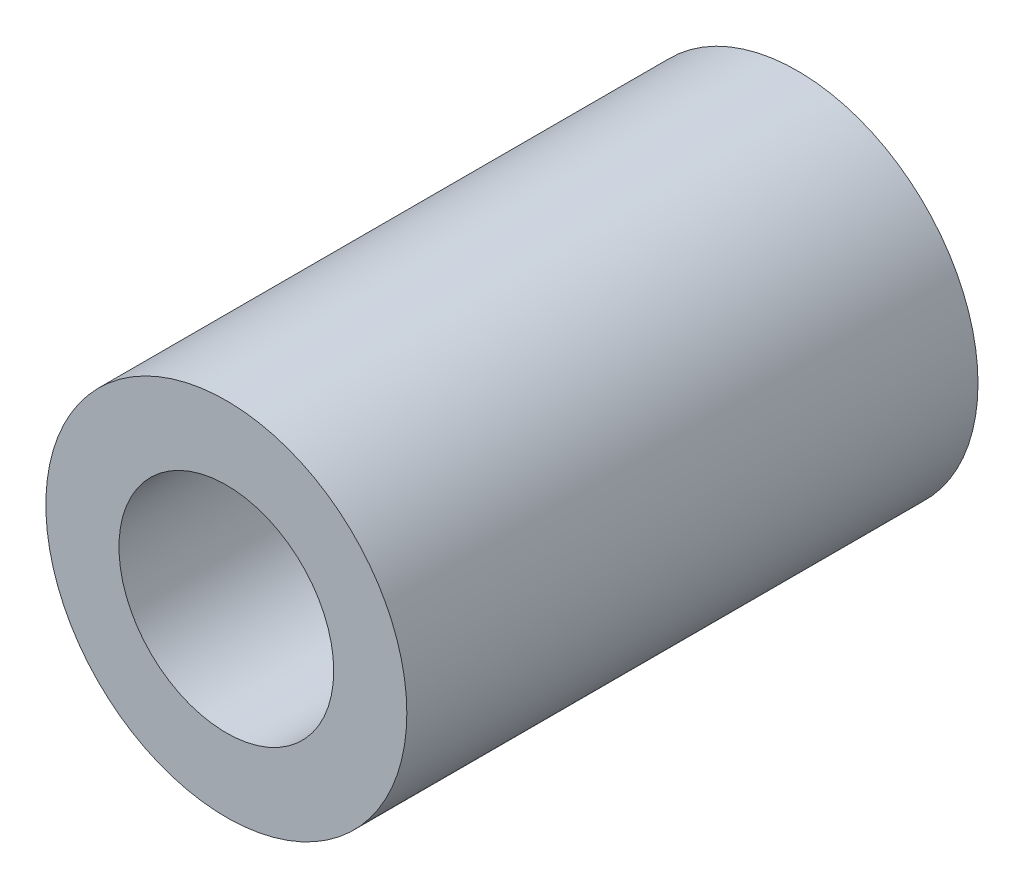
from build123d import *

# Parameters (mm, degrees)
SKETCH1_R           = 7.9
SKETCH1_R_2         = 4.7
BOSS_EXTRUDE1_DEPTH = 25


with BuildPart() as part:
    # Sketch1 → Boss-Extrude1 (new body)
    with BuildSketch(Plane.XY):
        Circle(SKETCH1_R)
        Circle(SKETCH1_R_2, mode=Mode.SUBTRACT)
    extrude(amount=-BOSS_EXTRUDE1_DEPTH)


solid = part.part
